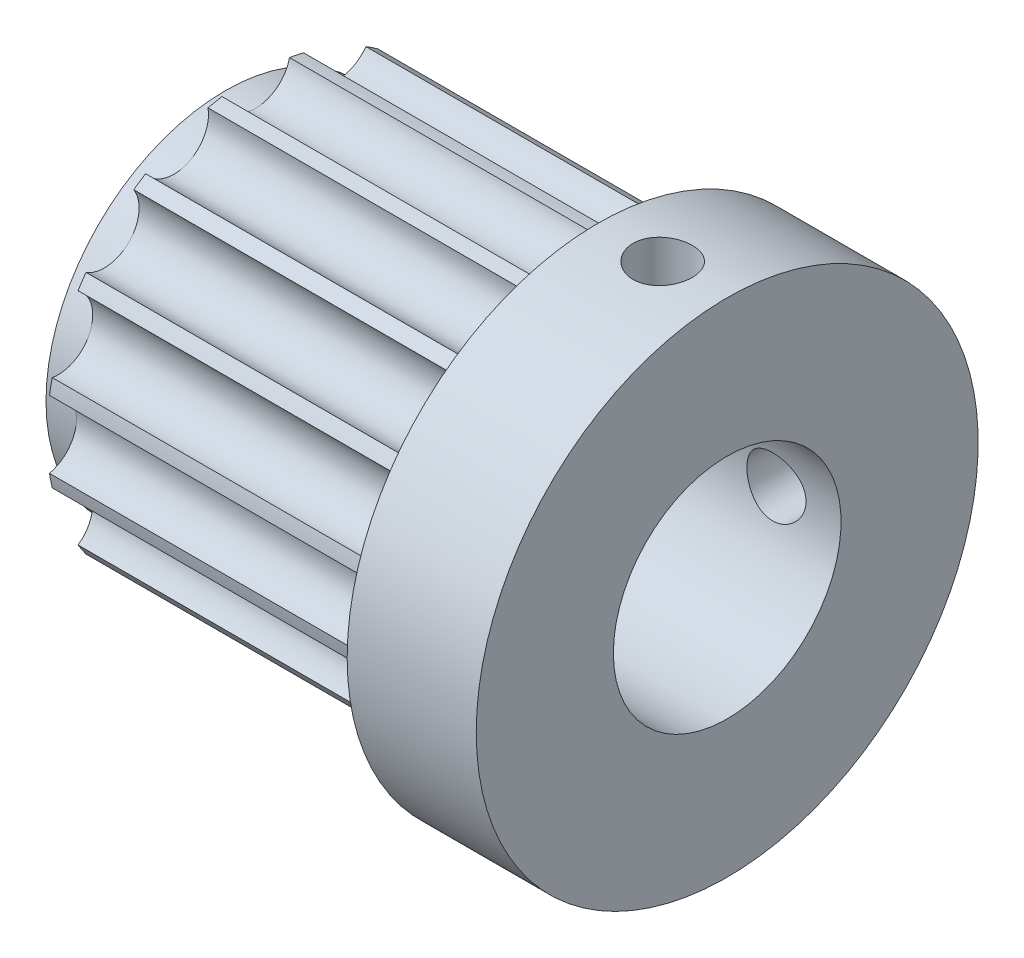
from build123d import *

# Parameters (mm, degrees)
SKETCH2_R          = 1.93
CUT_EXTRUDE1_DEPTH = 19.1
CIRPATTERN1_COUNT  = 16
SKETCH3_W          = 1.65
SKETCH3_H          = 14.001
CIRPATTERN2_COUNT  = 2
CIRPATTERN2_ANGLE  = 90


with BuildPart() as part:
    # Sketch1 → Revolve1 (revolve)
    with BuildSketch(Plane.XY):
        Polygon((-11.25, 6.35), (16.75, 6.35), (16.75, 14), (9.55, 14), (9.55, 11.66), (-9.55, 11.66), (-9.55, 10), (-11.25, 10), align=None)
    revolve(axis=Axis((0, 0, 0), (1, 0, 0)))

    # Sketch2 → Cut-Extrude1 (cut)
    with BuildSketch(Plane.ZY.offset(9.55)):
        with Locations((0, 11.93)):
            Circle(SKETCH2_R)
    cut_extrude1 = extrude(amount=-CUT_EXTRUDE1_DEPTH, mode=Mode.SUBTRACT)

    # CirPattern1: Cut-Extrude1 ×16 about axis
    cirpattern1_axis = Axis((0, 0, 0), (1, 0, 0))
    for i in range(1, CIRPATTERN1_COUNT):
        add(cut_extrude1.rotate(cirpattern1_axis, i * 360 / CIRPATTERN1_COUNT), mode=Mode.SUBTRACT)

    # Sketch3 → M4x0.7 Tapped Hole1 (revolve, cut)
    with BuildSketch(Plane(origin=(13.15, 0, 0), x_dir=(0, 0, -1), z_dir=(1, 0, 0))):
        with Locations((0.825, 7.0005)):
            Rectangle(SKETCH3_W, SKETCH3_H)
    m4x0_7_tapped_hole1 = revolve(axis=Axis((13.15, -6.35, 0), (0, 1, 0)), mode=Mode.SUBTRACT)

    # CirPattern2: M4x0.7 Tapped Hole1 ×2 about axis
    cirpattern2_axis = Axis((0, 0, 0), (-1, 0, 0))
    for i in range(1, CIRPATTERN2_COUNT):
        add(m4x0_7_tapped_hole1.rotate(cirpattern2_axis, i * CIRPATTERN2_ANGLE / (CIRPATTERN2_COUNT - 1)), mode=Mode.SUBTRACT)


solid = part.part
